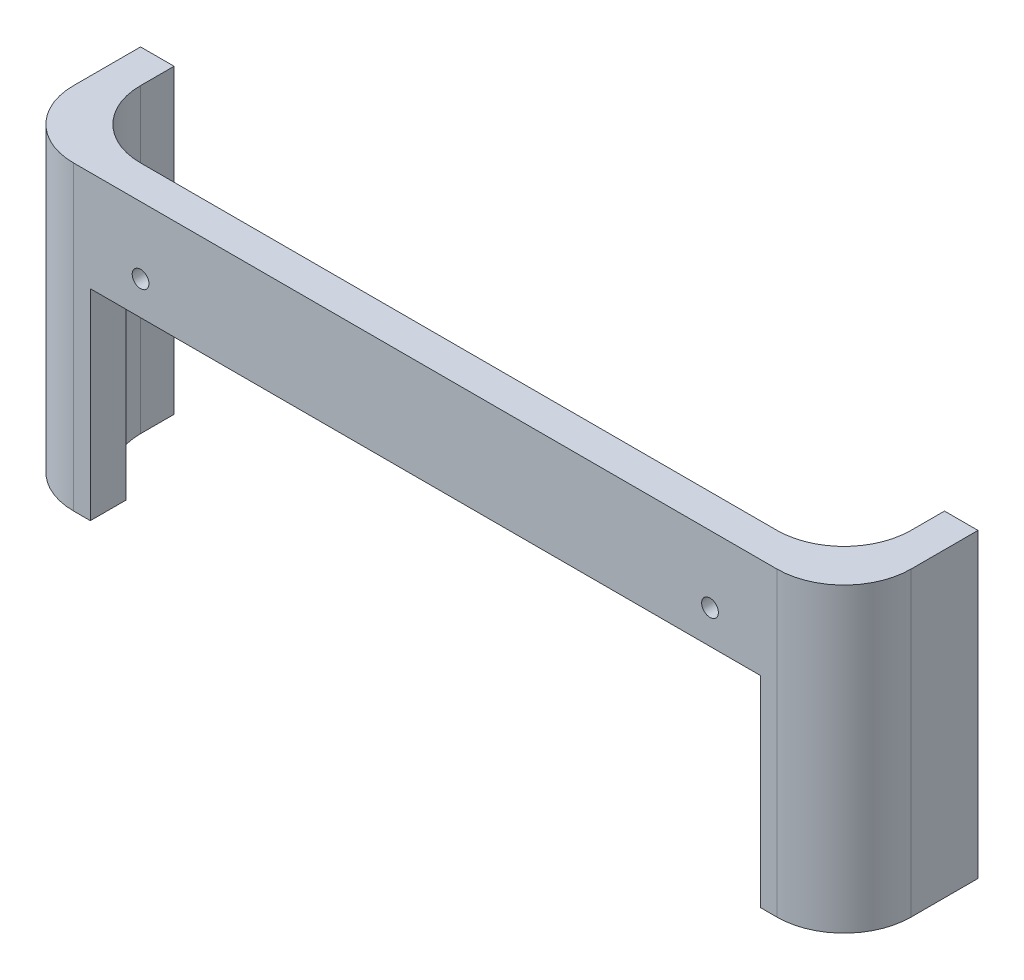
from build123d import *

# Parameters (mm, degrees)
SKETCH1_W               = 250
SKETCH1_H               = 250
SKETCH1_W_2             = 230
SKETCH1_H_2             = 230
BOSS_EXTRUDE1_DEPTH     = 90
SKETCH2_W               = 200
SKETCH2_H               = 60
CUT_EXTRUDE1_DEPTH      = 50
FILLET1_R               = 20
SKETCH10_W              = 210
SKETCH10_H              = 90
CUT_EXTRUDE6_DEPTH      = 1
CUT_EXTRUDE6_DEPTH_BACK = 251
SKETCH11_R              = 2.5
CUT_EXTRUDE7_DEPTH      = 10


with BuildPart() as part:
    # Sketch1 → Boss-Extrude1 (new body)
    with BuildSketch(Plane(origin=(0, 0, 0), x_dir=(1, 0, 0), z_dir=(0, 1, 0))):
        Rectangle(SKETCH1_W, SKETCH1_H)
        Rectangle(SKETCH1_W_2, SKETCH1_H_2, mode=Mode.SUBTRACT)
    extrude(amount=BOSS_EXTRUDE1_DEPTH)

    # Sketch2 → Cut-Extrude1 (cut)
    with BuildSketch(Plane.XY.offset(125)):
        with Locations((0, 30)):
            Rectangle(SKETCH2_W, SKETCH2_H)
    extrude(amount=-CUT_EXTRUDE1_DEPTH, mode=Mode.SUBTRACT)

    # Fillet1
    fillet1_edges = [part.edges().sort_by_distance(p)[0] for p in [
        (-115, 45, 115),
        (115, 45, 115),
        (115, 45, -115),
        (-115, 45, -115),
        (-125, 45, 125),
        (125, 45, 125),
        (125, 45, -125),
        (-125, 45, -125),
    ]]
    fillet(fillet1_edges, radius=FILLET1_R)

    # Sketch10 → Cut-Extrude6 (cut, two sides)
    with BuildSketch(Plane(origin=(125, 0, 0), x_dir=(0, 0, -1), z_dir=(1, 0, 0))) as cut_extrude6_sk:
        with Locations((20, 45)):
            Rectangle(SKETCH10_W, SKETCH10_H)
    extrude(amount=CUT_EXTRUDE6_DEPTH, mode=Mode.SUBTRACT)
    extrude(cut_extrude6_sk.sketch, amount=-CUT_EXTRUDE6_DEPTH_BACK, mode=Mode.SUBTRACT)

    # Sketch11 → Cut-Extrude7 (cut)
    with BuildSketch(Plane.XY.offset(125)):
        with Locations((-85, 70)):
            Circle(SKETCH11_R)
        with Locations((85, 70)):
            Circle(SKETCH11_R)
    extrude(amount=-CUT_EXTRUDE7_DEPTH, mode=Mode.SUBTRACT)


solid = part.part
